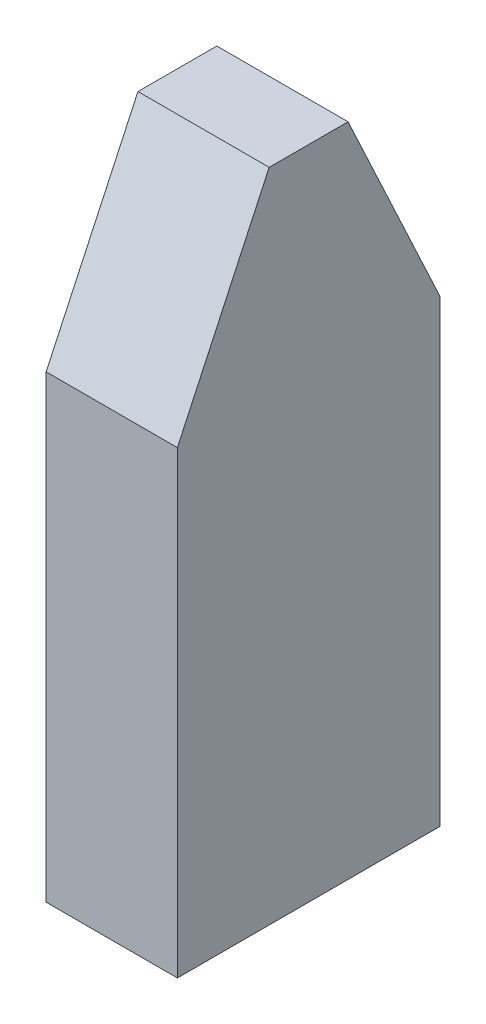
from build123d import *

# Parameters (mm, degrees)
SKETCH_1_W      = 10
SKETCH_1_H      = 20
EXTRUDE_1_DEPTH = 50
CHAMFER_1_SIZE  = 15
CHAMFER_1_SIZE2 = 6.994614872
CHAMFER_2_SIZE  = 15
CHAMFER_2_SIZE2 = 6.994614872


with BuildPart() as part:
    # Эскиз1 → Вытянуть1 (new body)
    with BuildSketch(Plane(origin=(0, 0, 0), x_dir=(1, 0, 0), z_dir=(0, 1, 0))):
        Rectangle(SKETCH_1_W, SKETCH_1_H)
    extrude(amount=EXTRUDE_1_DEPTH)

    # Фаска1
    chamfer_1_edges = [part.edges().sort_by_distance(p)[0] for p in [
        (0, 50, 10),
    ]]
    chamfer_1_side = [part.faces().sort_by_distance(p)[0] for p in [
        (0, 25, 10),
    ]]
    chamfer(chamfer_1_edges, length=CHAMFER_1_SIZE, length2=CHAMFER_1_SIZE2, reference=chamfer_1_side[0])

    # Фаска2
    chamfer_2_edges = [part.edges().sort_by_distance(p)[0] for p in [
        (0, 50, -10),
    ]]
    chamfer_2_side = [part.faces().sort_by_distance(p)[0] for p in [
        (0, 25, -10),
    ]]
    chamfer(chamfer_2_edges, length=CHAMFER_2_SIZE, length2=CHAMFER_2_SIZE2, reference=chamfer_2_side[0])


solid = part.part
